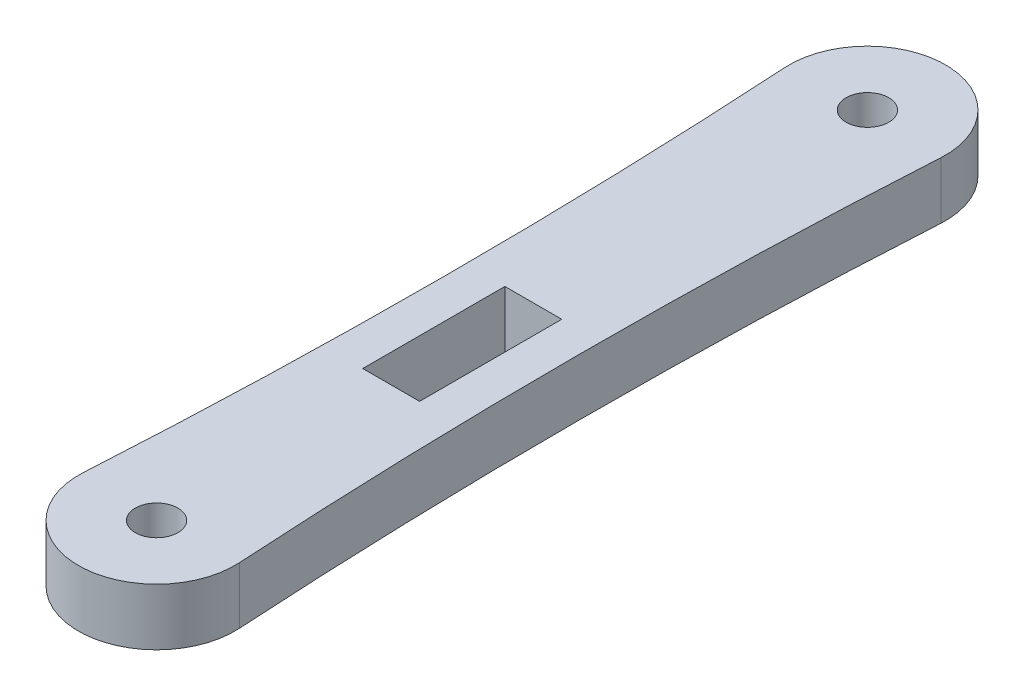
from build123d import *

# Parameters (mm, degrees)
SKETCH1_R           = 1.5
SKETCH1_W           = 4
SKETCH1_H           = 10
BOSS_EXTRUDE1_DEPTH = 4


with BuildPart() as part:
    # Sketch1 → Boss-Extrude1 (new body)
    with BuildSketch(Plane(origin=(0, 0, 0), x_dir=(1, 0, 0), z_dir=(0, 1, 0))):
        with BuildLine():
            ThreePointArc((-5.490108902, 0.329703267), (0, -5.5), (5.490108902, 0.329703267))
            ThreePointArc((5.490108902, 0.329703267), (4.75, 25), (5.490108902, 49.670296733))
            ThreePointArc((5.490108902, 49.670296733), (0, 55.5), (-5.490108902, 49.670296733))
            ThreePointArc((-5.490108902, 49.670296733), (-4.75, 25), (-5.490108902, 0.329703267))
        make_face()
        Circle(SKETCH1_R, mode=Mode.SUBTRACT)
        with Locations((0, 50)):
            Circle(SKETCH1_R, mode=Mode.SUBTRACT)
        with Locations((0, 21.5)):
            Rectangle(SKETCH1_W, SKETCH1_H, mode=Mode.SUBTRACT)
    extrude(amount=BOSS_EXTRUDE1_DEPTH)


solid = part.part
